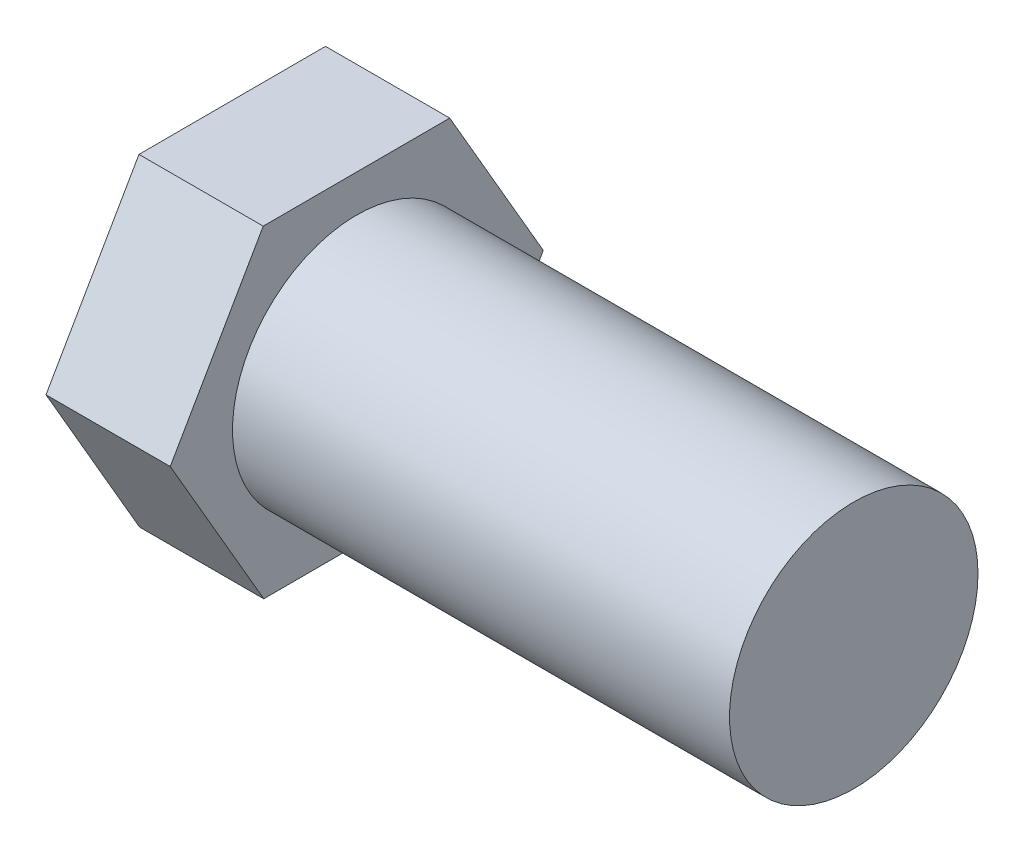
from build123d import *

# Parameters (mm, degrees)
EXTRUDE_1_DEPTH = 5
SKETCH_2_R      = 5
EXTRUDE_2_DEPTH = 20


with BuildPart() as part:
    # 草图1 → 凸台-拉伸1 (new body)
    with BuildSketch(Plane(origin=(0, 0, 0), x_dir=(0, 0, -1), z_dir=(1, 0, 0))):
        Polygon((3.764263516, -6.493354566), (7.505541768, 0.013270549), (3.741278251, 6.506625114), (-3.764263516, 6.493354566), (-7.505541768, -0.013270549), (-3.741278251, -6.506625114), align=None)
    extrude(amount=EXTRUDE_1_DEPTH)

    # 草图2 → 凸台-拉伸2 (add)
    with BuildSketch(Plane(origin=(5, 0, 0), x_dir=(0, 0, -1), z_dir=(1, 0, 0))):
        Circle(SKETCH_2_R)
    extrude(amount=EXTRUDE_2_DEPTH)


solid = part.part
